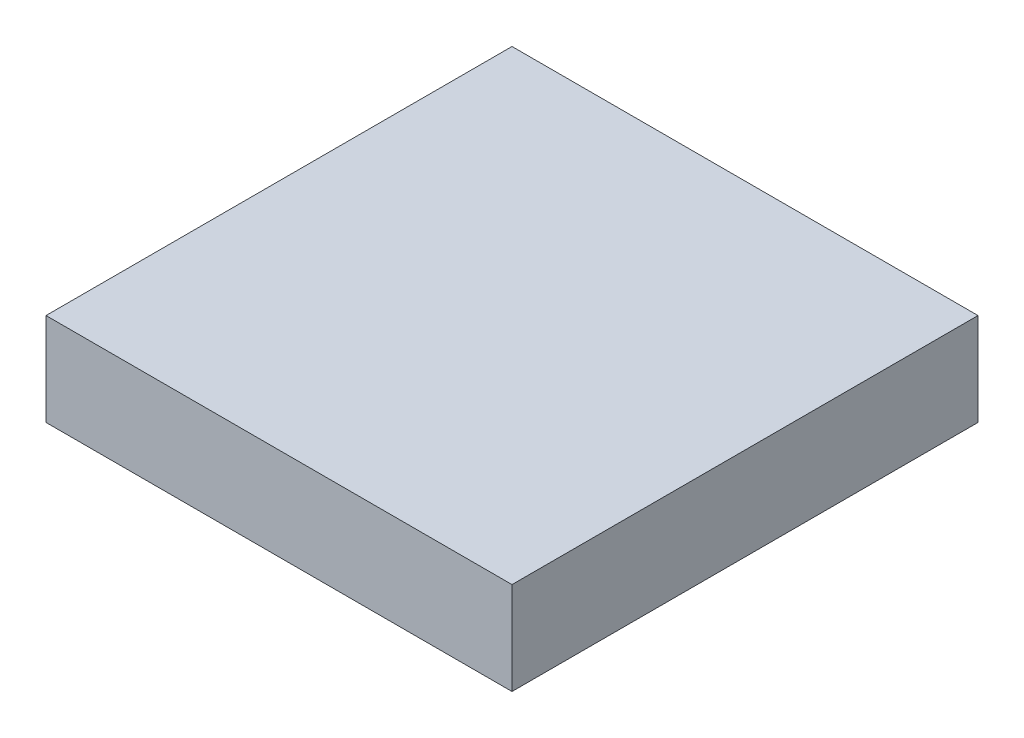
from build123d import *

# Parameters (mm, degrees)
SKETCH3_W           = 8
SKETCH3_H           = 8
BOSS_EXTRUDE1_DEPTH = 1.59


with BuildPart() as part:
    # Sketch3 → Boss-Extrude1 (new body)
    with BuildSketch(Plane(origin=(0, 0, 0), x_dir=(1, 0, 0), z_dir=(0, 1, 0))):
        with Locations((4, 4)):
            Rectangle(SKETCH3_W, SKETCH3_H)
    extrude(amount=BOSS_EXTRUDE1_DEPTH)


solid = part.part
